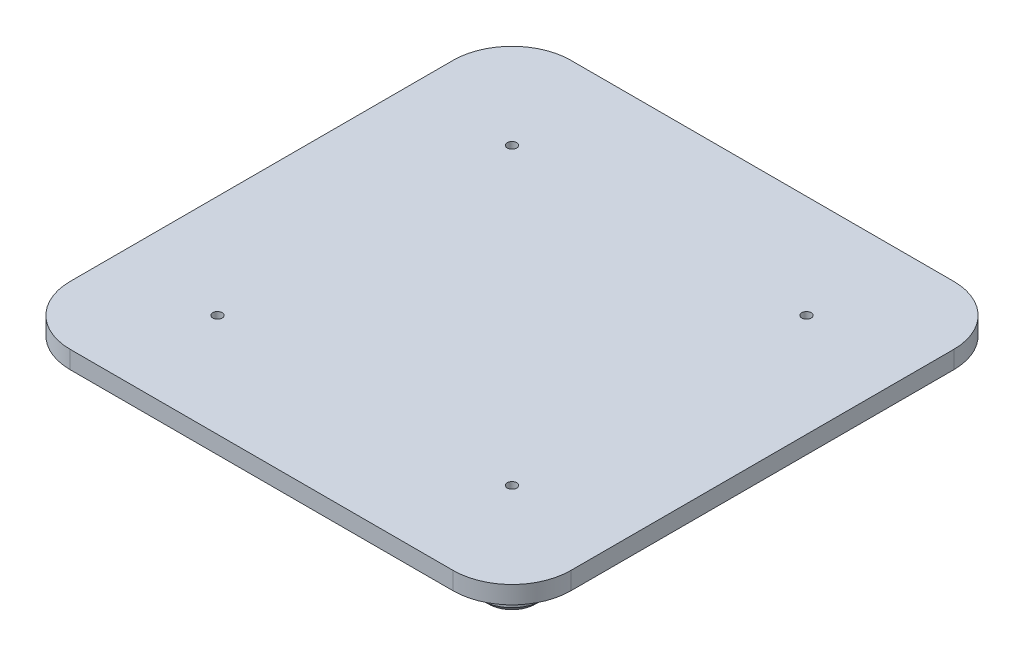
from build123d import *

# Parameters (mm, degrees)
SKETCH_1_W               = 74.9
SKETCH_1_H               = 74.9
SKETCH_1_W_2             = 66.9
SKETCH_1_H_2             = 66.9
EXTRUDE_1_DEPTH          = 5
SKETCH_2_W               = 85
SKETCH_2_H               = 85
EXTRUDE_2_DEPTH          = 3
FILLET_2_R               = 5
SKETCH_3_W               = 44.125802366
SKETCH_3_H               = 10
CUT_EXTRUDE_1_DEPTH      = 103
PATTERN_CIRCULAR_1_COUNT = 2
PATTERN_CIRCULAR_1_ANGLE = 90
FILLET_3_R               = 2
FILLET_4_R               = 2
FILLET_5_R               = 2
CHAMFER_1_SIZE           = 1
SKETCH_5_R               = 0.8
CUT_EXTRUDE_2_DEPTH      = 10
FILLET_9_R               = 10


with BuildPart() as part:
    # 草图1 → 凸台-拉伸1 (new body)
    with BuildSketch(Plane(origin=(0, 0, 0), x_dir=(1, 0, 0), z_dir=(0, 1, 0))):
        Rectangle(SKETCH_1_W, SKETCH_1_H)
        Rectangle(SKETCH_1_W_2, SKETCH_1_H_2, mode=Mode.SUBTRACT)
    extrude(amount=EXTRUDE_1_DEPTH)

    # 草图2 → 凸台-拉伸2 (add)
    with BuildSketch(Plane(origin=(0, 5, 0), x_dir=(1, 0, 0), z_dir=(0, 1, 0))):
        Rectangle(SKETCH_2_W, SKETCH_2_H)
    extrude(amount=EXTRUDE_2_DEPTH)

    # 圆角2
    fillet_2_edges = [part.edges().sort_by_distance(p)[0] for p in [
        (-37.45, 2.5, 37.45),
        (-37.45, 2.5, -37.45),
        (37.45, 2.5, -37.45),
        (37.45, 2.5, 37.45),
    ]]
    fillet(fillet_2_edges, radius=FILLET_2_R)

    # 草图3 → 切除-拉伸1 (cut, symmetric)
    with BuildSketch(Plane(origin=(0, 0, -37.45), x_dir=(-1, 0, 0), z_dir=(0, 0, -1))):
        Rectangle(SKETCH_3_W, SKETCH_3_H)
    cut_extrude_1 = extrude(amount=CUT_EXTRUDE_1_DEPTH, both=True, mode=Mode.SUBTRACT)

    # 阵列(圆周)1: 切除-拉伸1 ×2 about axis
    pattern_circular_1_axis = Axis((0, 0, 0), (0, -1, 0))
    for i in range(1, PATTERN_CIRCULAR_1_COUNT):
        add(cut_extrude_1.rotate(pattern_circular_1_axis, i * PATTERN_CIRCULAR_1_ANGLE / (PATTERN_CIRCULAR_1_COUNT - 1)), mode=Mode.SUBTRACT)

    # 圆角3
    fillet_3_edges = [part.edges().sort_by_distance(p)[0] for p in [
        (-33.45, 2.5, 33.45),
        (33.45, 2.5, 33.45),
        (33.45, 2.5, -33.45),
        (-33.45, 2.5, -33.45),
    ]]
    fillet(fillet_3_edges, radius=FILLET_3_R)

    # 圆角4
    fillet_4_edges = [part.edges().sort_by_distance(p)[0] for p in [
        (-22.062901183, 2.5, -37.45),
        (-37.45, 2.5, -22.062901183),
        (37.45, 2.5, -22.062901183),
        (22.062901183, 2.5, -37.45),
        (-37.45, 2.5, 22.062901183),
        (-22.062901183, 2.5, 37.45),
        (37.45, 2.5, 22.062901183),
        (22.062901183, 2.5, 37.45),
    ]]
    fillet(fillet_4_edges, radius=FILLET_4_R)

    # 圆角5
    fillet_5_edges = [part.edges().sort_by_distance(p)[0] for p in [
        (-26.756450591, 5, 33.45),
        (-32.864213562, 5, 32.864213562),
        (33.45, 5, 26.756450591),
        (26.756450591, 5, 33.45),
        (-33.45, 5, -26.756450591),
        (-32.864213562, 5, -32.864213562),
        (33.45, 5, -26.756450591),
        (32.864213562, 5, -32.864213562),
        (-33.45, 5, 26.756450591),
        (32.864213562, 5, 32.864213562),
        (-26.756450591, 5, -33.45),
        (26.756450591, 5, -33.45),
    ]]
    fillet(fillet_5_edges, radius=FILLET_5_R)

    # 倒角1
    chamfer_1_edges = [part.edges().sort_by_distance(p)[0] for p in [
        (-22.062901183, 0, 34.45),
        (-22.64868762, 0, 36.864213562),
        (-28.256450591, 0, 37.45),
        (-35.985533906, 0, 35.985533906),
        (-37.45, 0, 28.256450591),
        (-36.864213562, 0, 22.64868762),
        (-36.864213562, 0, -22.64868762),
        (-22.062901183, 0, -34.45),
        (-37.45, 0, -28.256450591),
        (-22.64868762, 0, -36.864213562),
        (-35.985533906, 0, -35.985533906),
        (-28.256450591, 0, -37.45),
        (36.864213562, 0, -22.64868762),
        (37.45, 0, -28.256450591),
        (35.985533906, 0, -35.985533906),
        (22.062901183, 0, -34.45),
        (28.256450591, 0, -37.45),
        (22.64868762, 0, -36.864213562),
        (36.864213562, 0, 22.64868762),
        (37.45, 0, 28.256450591),
        (35.985533906, 0, 35.985533906),
        (28.256450591, 0, 37.45),
        (22.062901183, 0, 34.45),
        (22.64868762, 0, 36.864213562),
    ]]
    chamfer(chamfer_1_edges, length=CHAMFER_1_SIZE)

    # 草图5 → 切除-拉伸2 (cut)
    with BuildSketch(Plane(origin=(0, 5, 0), x_dir=(-1, 0, 0), z_dir=(0, -1, 0))):
        with Locations((-25, 25)):
            Circle(SKETCH_5_R)
        with Locations((25, 25)):
            Circle(SKETCH_5_R)
        with Locations((25, -25)):
            Circle(SKETCH_5_R)
        with Locations((-25, -25)):
            Circle(SKETCH_5_R)
    extrude(amount=-CUT_EXTRUDE_2_DEPTH, mode=Mode.SUBTRACT)

    # 圆角9
    fillet_9_edges = [part.edges().sort_by_distance(p)[0] for p in [
        (42.5, 6.5, -42.5),
        (-42.5, 6.5, -42.5),
        (42.5, 6.5, 42.5),
        (-42.5, 6.5, 42.5),
    ]]
    fillet(fillet_9_edges, radius=FILLET_9_R)


solid = part.part
